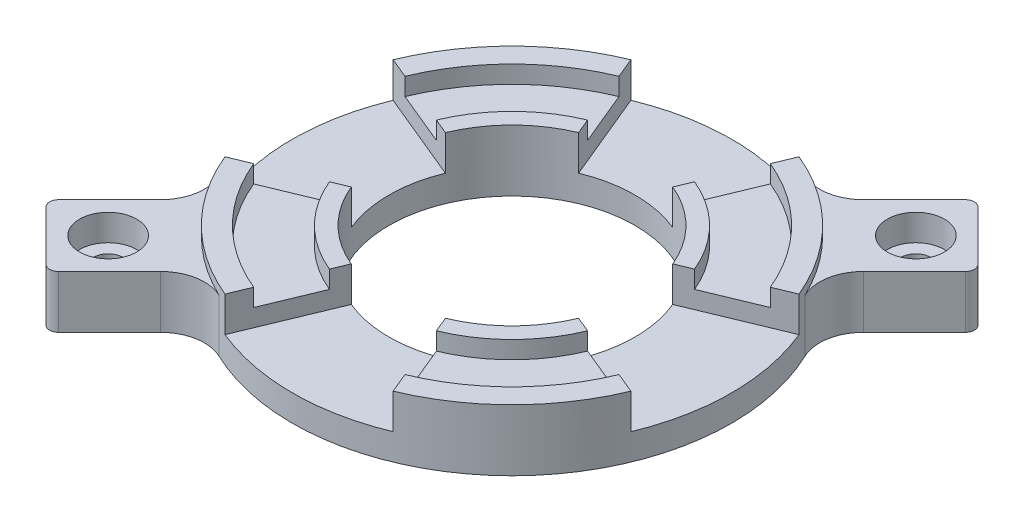
from build123d import *

# Parameters (mm, degrees)
SKETCH1_R                      = 25
SKETCH1_R_2                    = 14
BOSS_EXTRUDE1_DEPTH            = 5
SKETCH3_R                      = 25
SKETCH3_R_2                    = 22.5
BOSS_EXTRUDE2_DEPTH            = 2
SKETCH5_R                      = 15.9
SKETCH5_R_2                    = 14
BOSS_EXTRUDE3_DEPTH            = 2
CUT_EXTRUDE1_DEPTH             = 4
CIRPATTERN1_COUNT              = 4
BOSS_EXTRUDE4_DEPTH            = 6
CBORE_FOR_M3_SHCS1_D           = 3.4
CBORE_FOR_M3_SHCS1_DEPTH       = 6
CBORE_FOR_M3_SHCS1_CBORE_D     = 6.5
CBORE_FOR_M3_SHCS1_CBORE_DEPTH = 3
FILLET1_R                      = 5
FILLET1_OF_MIRROR1_R           = 5
FILLET2_R                      = 1


with BuildPart() as part:
    # Sketch1 → Boss-Extrude1 (new body)
    with BuildSketch(Plane(origin=(0, 0, 0), x_dir=(1, 0, 0), z_dir=(0, 1, 0))):
        Circle(SKETCH1_R)
        Circle(SKETCH1_R_2, mode=Mode.SUBTRACT)
    extrude(amount=BOSS_EXTRUDE1_DEPTH)

    # Sketch3 → Boss-Extrude2 (add)
    with BuildSketch(Plane(origin=(0, 5, 0), x_dir=(1, 0, 0), z_dir=(0, 1, 0))):
        Circle(SKETCH3_R)
        Circle(SKETCH3_R_2, mode=Mode.SUBTRACT)
    extrude(amount=BOSS_EXTRUDE2_DEPTH)

    # Sketch5 → Boss-Extrude3 (add, through all)
    with BuildSketch(Plane(origin=(0, 5, 0), x_dir=(1, 0, 0), z_dir=(0, 1, 0))):
        Circle(SKETCH5_R)
        Circle(SKETCH5_R_2, mode=Mode.SUBTRACT)
    extrude(amount=BOSS_EXTRUDE3_DEPTH)

    # Sketch4 → Cut-Extrude1 (cut)
    with BuildSketch(Plane(origin=(0, 7, 0), x_dir=(1, 0, 0), z_dir=(0, 1, 0))):
        with BuildLine():
            Line((0, 0), (-9.567085809, 23.096988313))
            ThreePointArc((-9.567085809, 23.096988313), (0, 25), (9.567085809, 23.096988313))
            Line((9.567085809, 23.096988313), (0, 0))
        make_face()
    cut_extrude1 = extrude(amount=-CUT_EXTRUDE1_DEPTH, mode=Mode.SUBTRACT)

    # CirPattern1: Cut-Extrude1 ×4 about axis
    cirpattern1_axis = Axis((0, 7, 0), (0, -1, 0))
    for i in range(1, CIRPATTERN1_COUNT):
        add(cut_extrude1.rotate(cirpattern1_axis, i * 360 / CIRPATTERN1_COUNT), mode=Mode.SUBTRACT)

    # Sketch6 → Boss-Extrude4 (add)
    with BuildSketch(Plane.XZ):
        with BuildLine():
            Line((-30.0520382, 22.980970389), (-22.980970389, 30.0520382))
            Line((-22.980970389, 30.0520382), (-13.78497417, 20.856041982))
            ThreePointArc((-13.78497417, 20.856041982), (-17.67766953, 17.67766953), (-20.856041982, 13.78497417))
            Line((-20.856041982, 13.78497417), (-30.0520382, 22.980970389))
        make_face()
    boss_extrude4 = extrude(amount=-BOSS_EXTRUDE4_DEPTH)

    # CBORE for M3 SHCS1
    with Locations(Plane(origin=(0, 6, 0), x_dir=(1, 0, 0), z_dir=(0, 1, 0))):
        with Locations((-22.980970389, -22.980970389)):
            cbore_for_m3_shcs1 = CounterBoreHole(CBORE_FOR_M3_SHCS1_D / 2, CBORE_FOR_M3_SHCS1_CBORE_D / 2, CBORE_FOR_M3_SHCS1_CBORE_DEPTH, depth=CBORE_FOR_M3_SHCS1_DEPTH)

    # Fillet1
    fillet1_edges = [part.edges().sort_by_distance(p)[0] for p in [
        (-20.856041982, 3, 13.78497417),
        (-13.78497417, 3, 20.856041982),
    ]]
    fillet(fillet1_edges, radius=FILLET1_R)

    # Mirror1: Boss-Extrude4, CBORE for M3 SHCS1 across plane
    add(boss_extrude4.mirror(Plane(origin=(0, 0, 0), x_dir=(0.707106781, 0, 0.707106781), z_dir=(-0.707106781, 0, 0.707106781))))
    add(cbore_for_m3_shcs1.mirror(Plane(origin=(0, 0, 0), x_dir=(0.707106781, 0, 0.707106781), z_dir=(-0.707106781, 0, 0.707106781))), mode=Mode.SUBTRACT)

    # Fillet1 of Mirror1
    fillet1_of_mirror1_edges = [part.edges().sort_by_distance(p)[0] for p in [
        (13.78497417, 3, -20.856041982),
        (20.856041982, 3, -13.78497417),
    ]]
    fillet(fillet1_of_mirror1_edges, radius=FILLET1_OF_MIRROR1_R)

    # Fillet2
    fillet2_edges = [part.edges().sort_by_distance(p)[0] for p in [
        (-30.0520382, 3, 22.980970389),
        (-22.980970389, 3, 30.0520382),
        (22.980970389, 3, -30.0520382),
        (30.0520382, 3, -22.980970389),
    ]]
    fillet(fillet2_edges, radius=FILLET2_R)


solid = part.part
